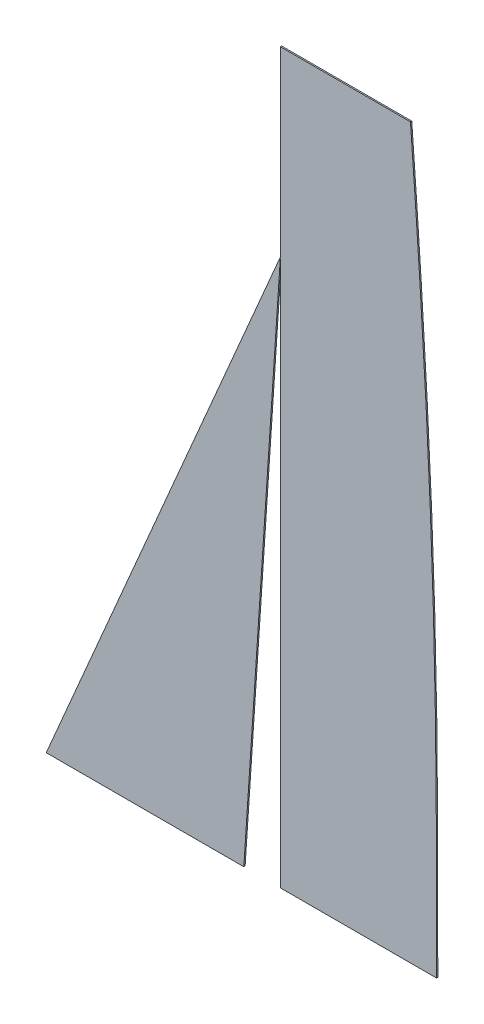
from build123d import *

# Parameters (mm, degrees)
BOSS_EXTRUDE1_DEPTH = 2.54
BOSS_EXTRUDE3_DEPTH = 2.54


with BuildPart() as part:
    # Sketch1 → Boss-Extrude1 (new body)
    with BuildSketch(Plane.XY):
        with BuildLine():
            Line((0, 0), (0, 1422.4))
            Line((0, 1422.4), (254, 1422.4))
            add(Edge.make_bspline(
                [(254, 1422.4), (307.286819, 718.686132178), (304.8, 400.693352615), (304.8, 0)],
                knots=[0, 0, 0, 0, 1, 1, 1, 1], degree=3))
            Line((304.8, 0), (0, 0))
        make_face()
    extrude(amount=BOSS_EXTRUDE1_DEPTH)


with BuildPart() as body_2:
    # Sketch2 → Boss-Extrude3 (new body)
    with BuildSketch(Plane.XY):
        Polygon((-71.373524572, 0), (0, 1066.8), (-457.2, 0), align=None)
    extrude(amount=BOSS_EXTRUDE3_DEPTH)


solid = Compound([part.part, body_2.part])
